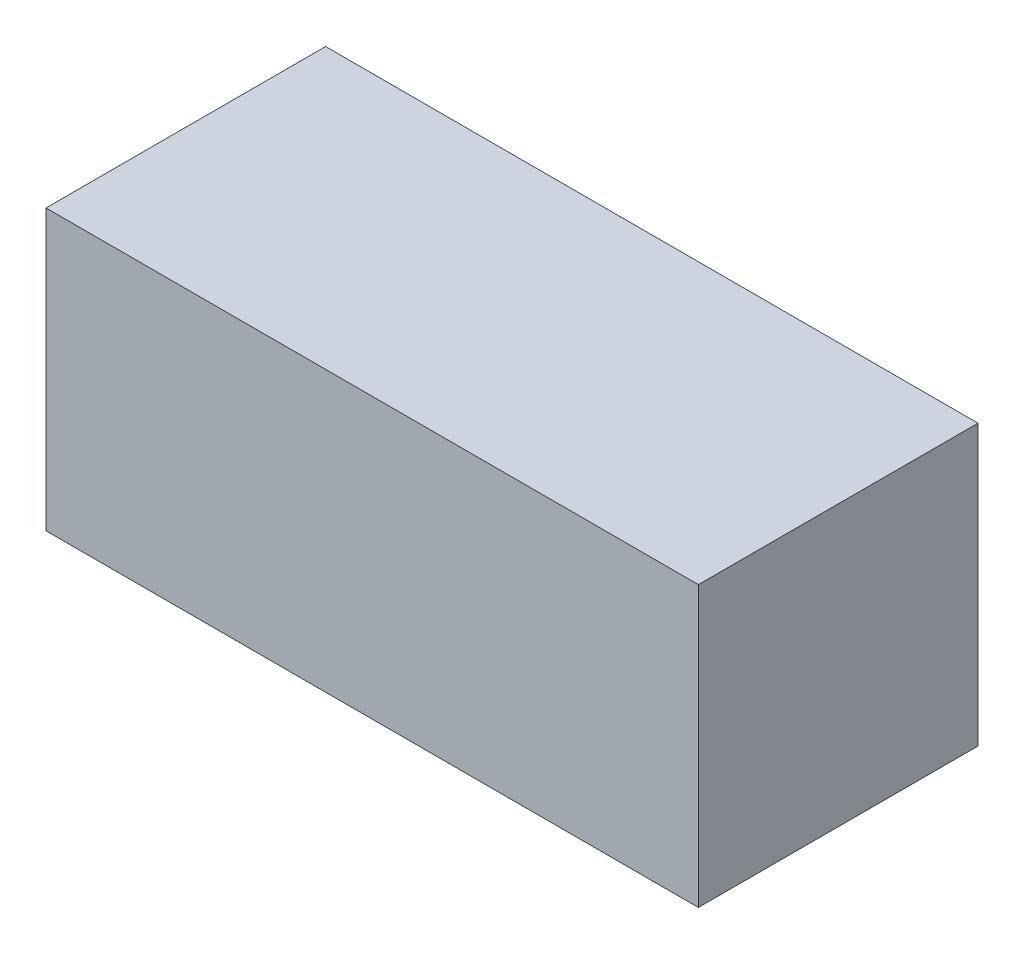
from build123d import *

# Parameters (mm, degrees)
SKETCH1_W           = 88.9
SKETCH1_H           = 38.1
BOSS_EXTRUDE1_DEPTH = 38.1


with BuildPart() as part:
    # Sketch1 → Boss-Extrude1 (new body)
    with BuildSketch(Plane(origin=(0, 0, 0), x_dir=(1, 0, 0), z_dir=(0, 1, 0))):
        Rectangle(SKETCH1_W, SKETCH1_H)
    extrude(amount=BOSS_EXTRUDE1_DEPTH)


solid = part.part
